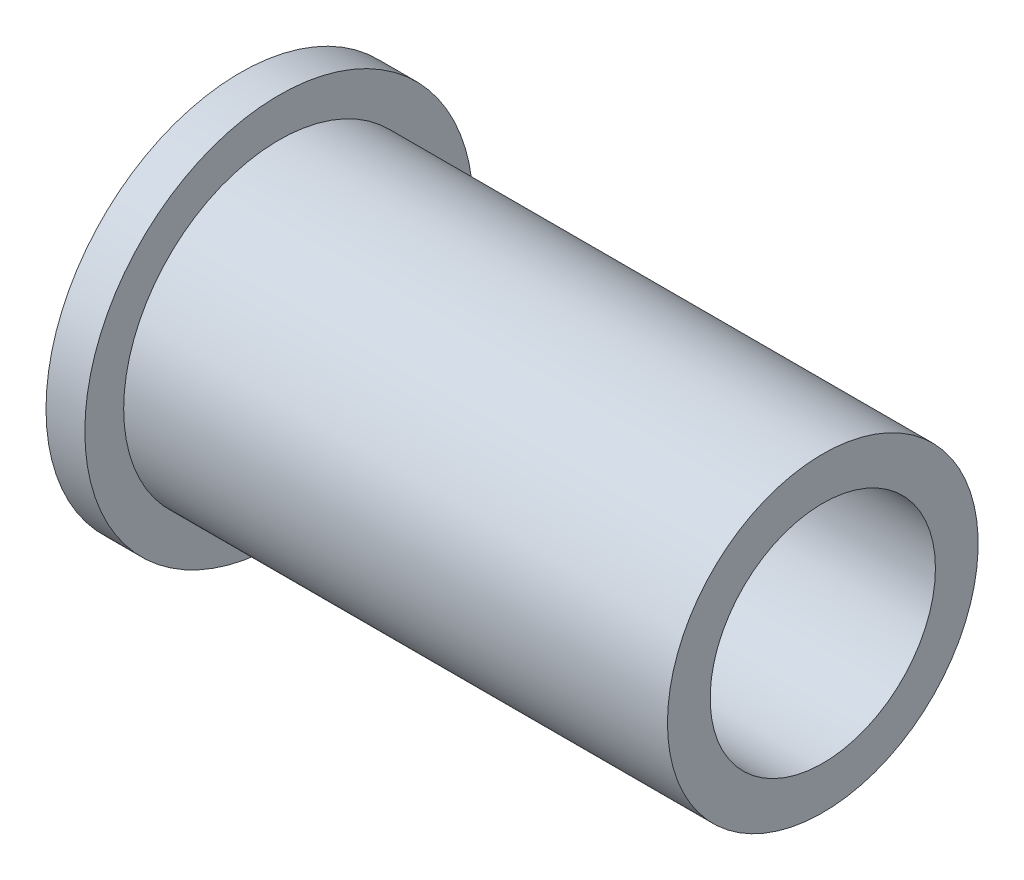
from build123d import *

# Parameters (mm, degrees)
FURO_COM_FOLGA_DE_M51_D     = 5.8
FURO_COM_FOLGA_DE_M51_DEPTH = 6
FURO_COM_FOLGA_DE_M51_TIP   = 1.171676055
DOMO1_FACE_RADIUS           = 5
DOMO1_HEIGHT                = 0.5


with BuildPart() as part:
    # Sketch2 → Revolve1 (revolve)
    with BuildSketch(Plane.XY):
        Polygon((-10, 0), (-10, 5), (-9, 5), (-9, 4), (5, 4), (5, 0), align=None)
    revolve(axis=Axis((-33.61911958, 0, 0), (1, 0, 0)))

    # Furo com folga de M51
    with Locations(Plane(origin=(5, 0, 0), x_dir=(0, 0, -1), z_dir=(1, 0, 0))):
        with Locations((0, 0)):
            Hole(FURO_COM_FOLGA_DE_M51_D / 2, depth=FURO_COM_FOLGA_DE_M51_DEPTH)
            with Locations((0, 0, -(FURO_COM_FOLGA_DE_M51_DEPTH + FURO_COM_FOLGA_DE_M51_TIP / 2))):  # 136° drill point
                Cone(0, FURO_COM_FOLGA_DE_M51_D / 2, FURO_COM_FOLGA_DE_M51_TIP, mode=Mode.SUBTRACT)

    # Domo1: a dome of height H over a round flat face of radius A is a cap of a sphere of radius (A * A + H * H) / (2 * H)
    domo1_r = (DOMO1_FACE_RADIUS * DOMO1_FACE_RADIUS + DOMO1_HEIGHT * DOMO1_HEIGHT) / (2 * DOMO1_HEIGHT)
    domo1_base = Plane((-10, 0, 0), z_dir=(-1, 0, 0))
    with Locations(domo1_base.offset(DOMO1_HEIGHT - domo1_r)):
        domo1_ball = Sphere(domo1_r, mode=Mode.PRIVATE)
    add(split(domo1_ball, bisect_by=domo1_base, keep=Keep.TOP, mode=Mode.PRIVATE))


solid = part.part
